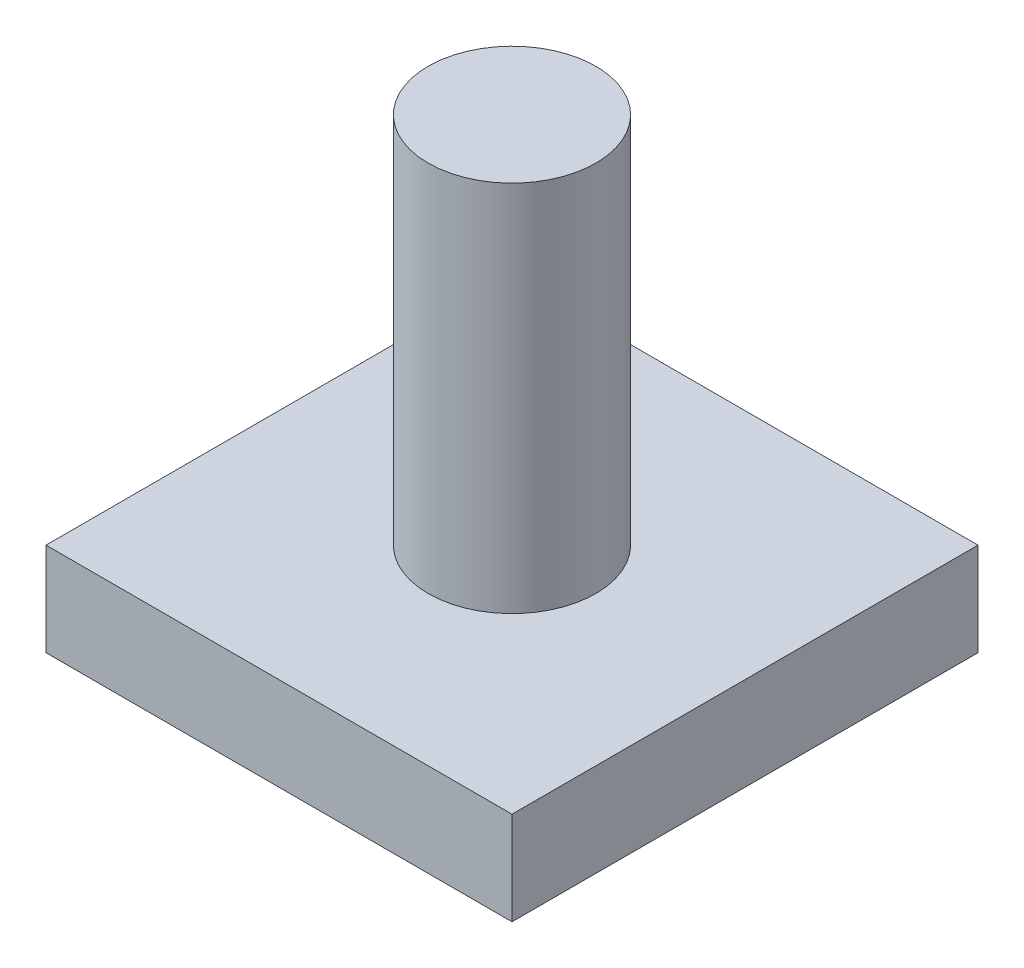
from build123d import *

# Parameters (mm, degrees)
SKETCH1_W           = 5
SKETCH1_H           = 5
BOSS_EXTRUDE1_DEPTH = 1
SKETCH2_R           = 0.9
BOSS_EXTRUDE2_DEPTH = 5


with BuildPart() as part:
    # Sketch1 → Boss-Extrude1 (new body)
    with BuildSketch(Plane(origin=(0, 0, 0), x_dir=(1, 0, 0), z_dir=(0, 1, 0))):
        Rectangle(SKETCH1_W, SKETCH1_H)
    extrude(amount=BOSS_EXTRUDE1_DEPTH)

    # Sketch2 → Boss-Extrude2 (add)
    with BuildSketch(Plane(origin=(0, 0, 0), x_dir=(1, 0, 0), z_dir=(0, 1, 0))):
        Circle(SKETCH2_R)
    extrude(amount=BOSS_EXTRUDE2_DEPTH)


solid = part.part
